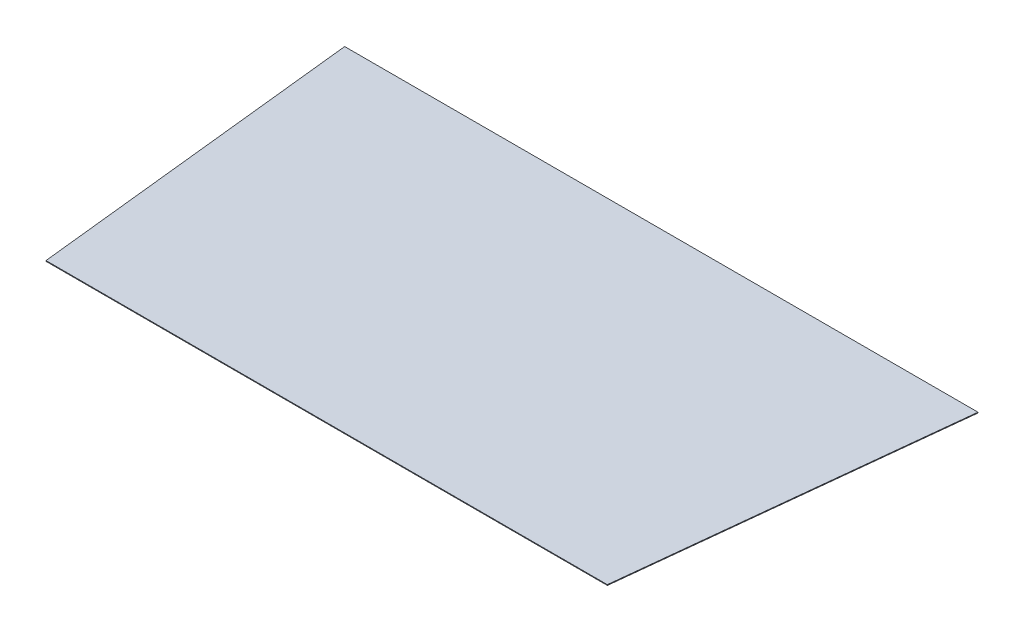
from build123d import *

# Parameters (mm, degrees)
BOSS_EXTRUDE1_DEPTH = 1


with BuildPart() as part:
    # Sketch1 → Boss-Extrude1 (new body)
    with BuildSketch(Plane(origin=(0, 0, 0), x_dir=(1, 0, 0), z_dir=(0, 1, 0))):
        Polygon((-292.713203141, 159.147439759), (587.286796859, 159.147439759), (537.286796859, -305.852560241), (-242.713203141, -305.852560241), align=None)
    extrude(amount=BOSS_EXTRUDE1_DEPTH)


solid = part.part
